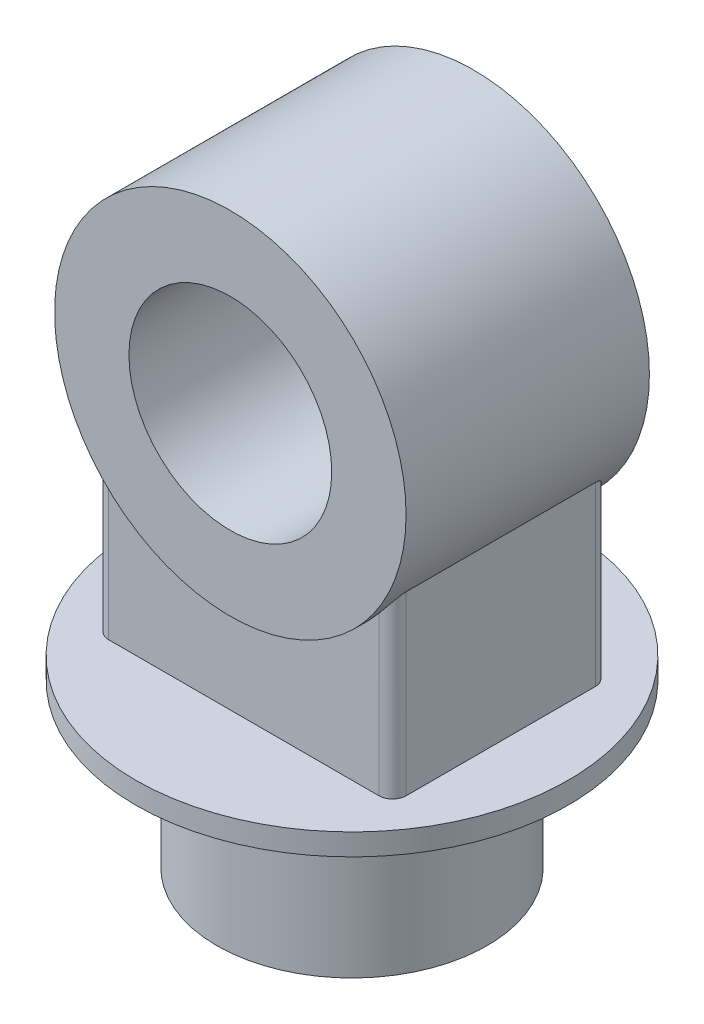
from build123d import *

# Parameters (mm, degrees)
SKETCH1_R                = 100
BOSS_EXTRUDE1_DEPTH      = 120
SKETCH2_R                = 160
BOSS_EXTRUDE3_DEPTH      = 16
SKETCH3_R                = 130
SKETCH3_R_2              = 75
BOSS_EXTRUDE4_DEPTH      = 90
BOSS_EXTRUDE5_REACH      = 402.125
BOSS_EXTRUDE5_END_RADIUS = 130
SKETCH4_W                = 220
SKETCH4_H                = 160
FILLET1_R                = 10


with BuildPart() as part:
    # Sketch1 → Boss-Extrude1 (new body)
    with BuildSketch(Plane(origin=(0, 0, 0), x_dir=(1, 0, 0), z_dir=(0, 1, 0))):
        with Locations(Location((0, 0, 0), (0, 0, 270))):
            Circle(SKETCH1_R)
    extrude(amount=BOSS_EXTRUDE1_DEPTH)

    # Sketch2 → Boss-Extrude3 (add)
    with BuildSketch(Plane(origin=(0, 120, 0), x_dir=(1, 0, 0), z_dir=(0, 1, 0))):
        with Locations(Location((0, 0, 0), (0, 0, 270))):
            Circle(SKETCH2_R)
    extrude(amount=BOSS_EXTRUDE3_DEPTH)



with BuildPart() as body_2:
    # Sketch3 → Boss-Extrude4 (new, symmetric)
    with BuildSketch(Plane.XY):
        with Locations(Location((0, 336, 0), (0, 0, 180))):
            Circle(SKETCH3_R)
        with Locations(Location((0, 336, 0), (0, 0, 180))):
            Circle(SKETCH3_R_2, mode=Mode.SUBTRACT)
    extrude(amount=BOSS_EXTRUDE4_DEPTH, both=True)


with BuildPart() as part_1:
    add(part.part)

    add(body_2.part)  # Boss-Extrude5 merges body 2
    # Boss-Extrude5: up to this cylinder (the profile starts outside it)
    boss_extrude5_end = Plane(origin=(0, 336, 0), z_dir=(0, 0, -1)) * Cylinder(BOSS_EXTRUDE5_END_RADIUS, 1065.25, mode=Mode.PRIVATE)
    # Sketch4 → Boss-Extrude5 (add, up to the surface)
    with BuildSketch(Plane(origin=(0, 136, 0), x_dir=(1, 0, 0), z_dir=(0, 1, 0)), mode=Mode.PRIVATE) as boss_extrude5_sk1:
        Rectangle(SKETCH4_W, SKETCH4_H)
    boss_extrude5_tool1 = extrude(boss_extrude5_sk1.sketch, amount=BOSS_EXTRUDE5_REACH, mode=Mode.PRIVATE) - boss_extrude5_end
    add(boss_extrude5_tool1.solids().sort_by_distance((0, 136, 0))[0])

    # Fillet1
    fillet1_edges = [part_1.edges().sort_by_distance(p)[0] for p in [
        (110, 201.358983849, -80),
        (110, 201.358983849, 80),
        (-110, 201.358983849, -80),
        (-110, 201.358983849, 80),
    ]]
    fillet(fillet1_edges, radius=FILLET1_R)


solid = part_1.part
